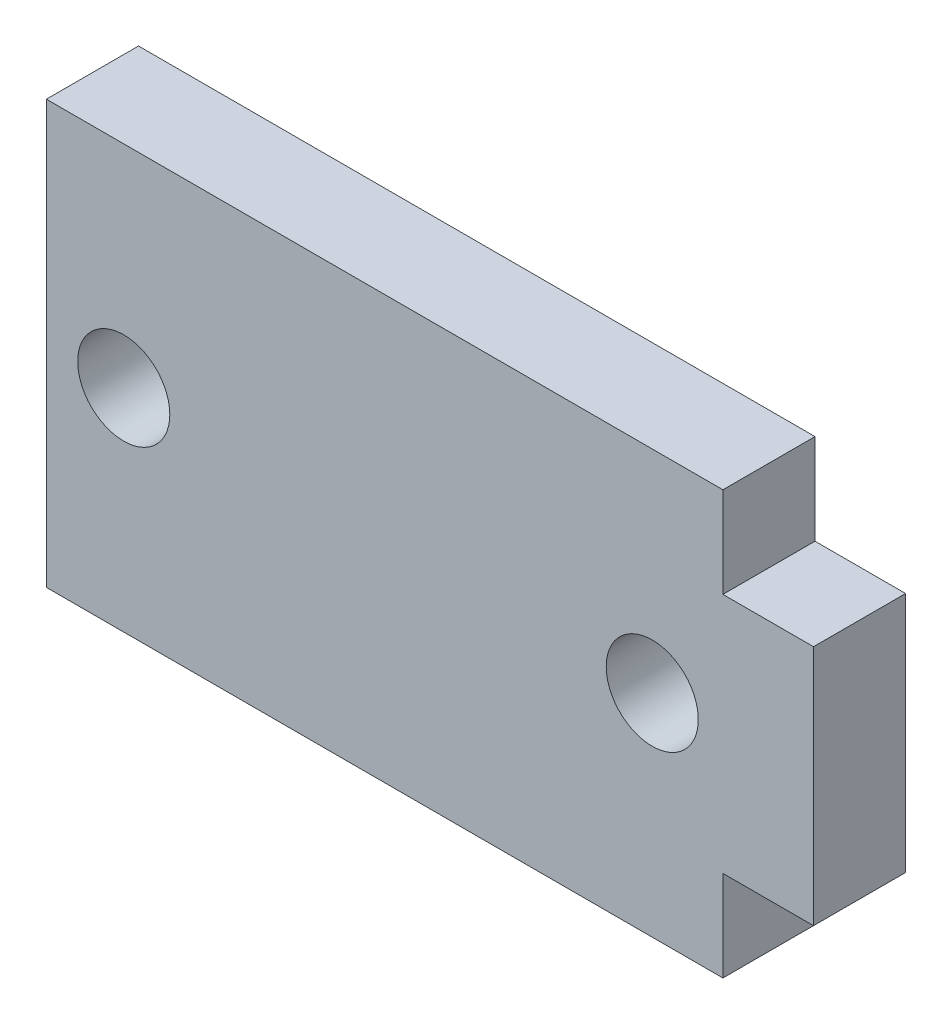
from build123d import *

# Parameters (mm, degrees)
SKETCH1_R           = 1.525
BOSS_EXTRUDE1_DEPTH = 3.05


with BuildPart() as part:
    # Sketch1 → Boss-Extrude1 (new body)
    with BuildSketch(Plane.XY):
        Polygon((-11.2, 20), (11.2, 20), (11.2, 17), (14.2, 17), (14.2, 9), (11.2, 9), (11.2, 6), (-11.2, 6), align=None)
        with Locations((8.861437687, 13)):
            Circle(SKETCH1_R, mode=Mode.SUBTRACT)
        with Locations((-8.638562313, 13)):
            Circle(SKETCH1_R, mode=Mode.SUBTRACT)
    extrude(amount=BOSS_EXTRUDE1_DEPTH)


solid = part.part
